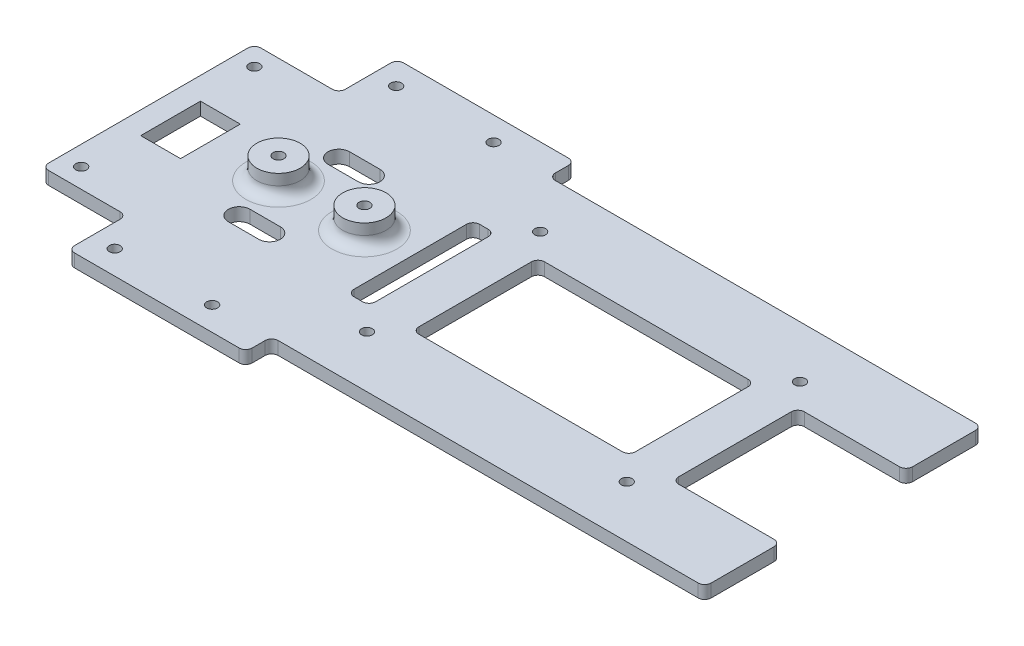
from build123d import *

# Parameters (mm, degrees)
SKETCH1_R           = 1.25
BOSS_EXTRUDE1_DEPTH = 3
SKETCH2_R           = 5
BOSS_EXTRUDE2_DEPTH = 5
FILLET1_R           = 2.5
SKETCH3_W           = 5
SKETCH3_H           = 29
SKETCH3_W_2         = 9.2
SKETCH3_H_2         = 13.8
SKETCH3_W_3         = 25
SKETCH3_W_4         = 50
SKETCH3_R           = 1.25
CUT_EXTRUDE1_DEPTH  = 127.602725089
FILLET2_R           = 1.5


with BuildPart() as part:
    # Sketch1 → Boss-Extrude1 (new body)
    with BuildSketch(Plane(origin=(0, 0, 0), x_dir=(1, 0, 0), z_dir=(0, 1, 0))):
        Polygon((-20.5, -38), (20.5, -38), (20.5, -32), (120.5, -32), (120.5, 32), (20.5, 32), (20.5, 38), (-20.5, 38), (-20.5, 24.5), (-40, 24.5), (-40, -24.5), (-20.5, -24.5), align=None)
        with Locations((-35.5, 20)):
            Circle(SKETCH1_R, mode=Mode.SUBTRACT)
        with Locations((-35.5, -20)):
            Circle(SKETCH1_R, mode=Mode.SUBTRACT)
    extrude(amount=BOSS_EXTRUDE1_DEPTH)

    # Sketch2 → Boss-Extrude2 (add)
    with BuildSketch(Plane(origin=(0, 3, 0), x_dir=(1, 0, 0), z_dir=(0, 1, 0))):
        with Locations((-9.925, 0)):
            Circle(SKETCH2_R)
        with Locations((9.925, 0)):
            Circle(SKETCH2_R)
    extrude(amount=BOSS_EXTRUDE2_DEPTH)

    # Fillet1
    fillet1_edges = [part.edges().sort_by_distance(p)[0] for p in [
        (4.925, 3, 0),
        (-14.925, 3, 0),
    ]]
    fillet(fillet1_edges, radius=FILLET1_R)

    # Sketch3 → Cut-Extrude1 (cut, through all)
    with BuildSketch(Plane(origin=(0, 0, 0), x_dir=(-1, 0, 0), z_dir=(0, -1, 0))):
        with Locations((-23, 0)):
            Rectangle(SKETCH3_W, SKETCH3_H)
        with BuildLine():
            Line((0.5, 9), (7.5, 9))
            ThreePointArc((7.5, 9), (10, 11.5), (7.5, 14))
            Line((7.5, 14), (0.5, 14))
            ThreePointArc((0.5, 14), (-2, 11.5), (0.5, 9))
        make_face()
        with BuildLine():
            Line((0.5, -14), (7.5, -14))
            ThreePointArc((7.5, -14), (10, -11.5), (7.5, -9))
            Line((7.5, -9), (0.5, -9))
            ThreePointArc((0.5, -9), (-2, -11.5), (0.5, -14))
        make_face()
        with Locations((30.25, 0)):
            Rectangle(SKETCH3_W_2, SKETCH3_H_2)
        with Locations((-108, 0)):
            Rectangle(SKETCH3_W_3, SKETCH3_H)
        with Locations((-60.5, 0)):
            Rectangle(SKETCH3_W_4, SKETCH3_H)
        with Locations((-30.5, -20)):
            Circle(SKETCH3_R)
        with Locations((-90.5, -20)):
            Circle(SKETCH3_R)
        with Locations((-30.5, 20)):
            Circle(SKETCH3_R)
        with Locations((-90.5, 20)):
            Circle(SKETCH3_R)
        with Locations((-7.25, 32.5)):
            Circle(SKETCH3_R)
        with Locations((15.25, 32.5)):
            Circle(SKETCH3_R)
        with Locations((-9.925, 0)):
            Circle(SKETCH3_R)
        with Locations((9.925, 0)):
            Circle(SKETCH3_R)
        with Locations((15.25, -32.5)):
            Circle(SKETCH3_R)
        with Locations((-7.25, -32.5)):
            Circle(SKETCH3_R)
    extrude(amount=-CUT_EXTRUDE1_DEPTH, mode=Mode.SUBTRACT)

    # Fillet2
    fillet2_edges = [part.edges().sort_by_distance(p)[0] for p in [
        (120.5, 1.5, -32),
        (120.5, 1.5, 32),
        (20.5, 1.5, -32),
        (20.5, 1.5, 32),
        (20.5, 1.5, 38),
        (-20.5, 1.5, 38),
        (20.5, 1.5, -38),
        (-40, 1.5, 24.5),
        (-20.5, 1.5, -24.5),
        (-20.5, 1.5, 24.5),
        (-20.5, 1.5, -38),
        (-40, 1.5, -24.5),
        (95.5, 1.5, 14.5),
        (95.5, 1.5, -14.5),
        (35.5, 1.5, -14.5),
        (85.5, 1.5, -14.5),
        (85.5, 1.5, 14.5),
        (35.5, 1.5, 14.5),
        (20.5, 1.5, 14.5),
        (25.5, 1.5, 14.5),
        (20.5, 1.5, -14.5),
        (25.5, 1.5, -14.5),
        (120.5, 1.5, 14.5),
        (120.5, 1.5, -14.5),
    ]]
    fillet(fillet2_edges, radius=FILLET2_R)


solid = part.part
